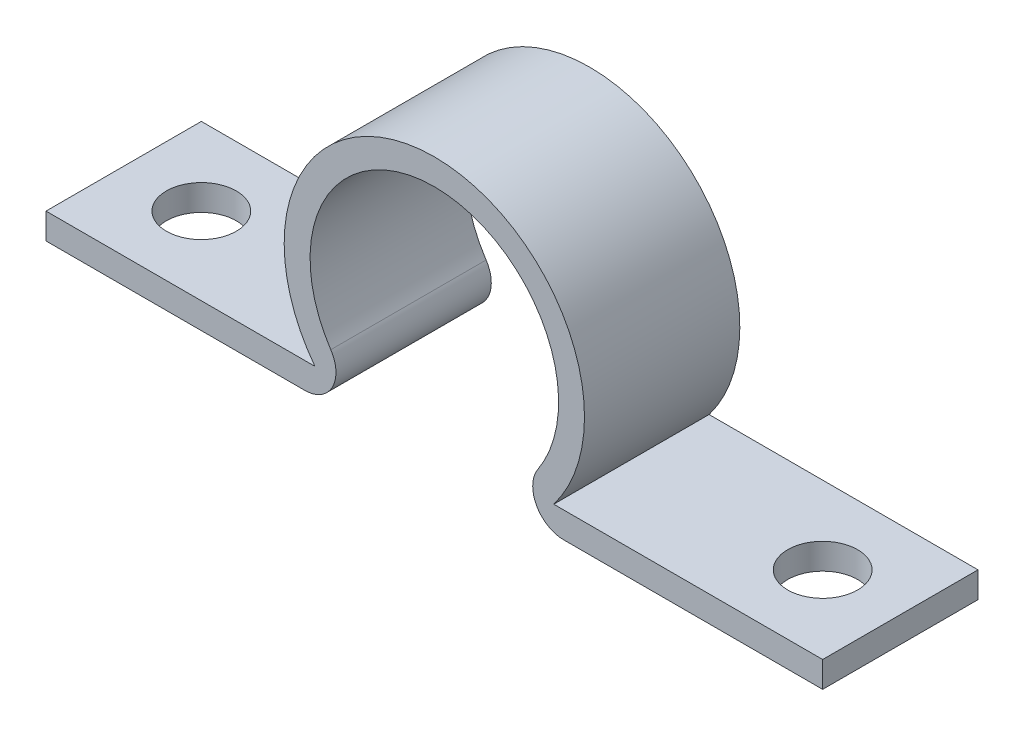
from build123d import *

# Parameters (mm, degrees)
BOSS_EXTRUDE1_DEPTH   = 30
M12_CLEARANCE_HOLE2_D = 13.5


with BuildPart() as part:
    # Sketch1 → Boss-Extrude1 (new body)
    with BuildSketch(Plane.XY):
        with BuildLine():
            Line((0, 0), (50, 0))
            ThreePointArc((50, 0), (55.286764074, 3.162725669), (55, 9.31662479))
            ThreePointArc((55, 9.31662479), (75, 46.583123952), (95, 9.31662479))
            ThreePointArc((95, 9.31662479), (94.713235926, 3.162725669), (100, 0))
            Line((100, 0), (150, 0))
            Line((150, 0), (150, 5))
            Line((150, 5), (98.061521027, 5))
            ThreePointArc((98.061521027, 5), (75, 51.583123952), (51.938478973, 5))
            Line((51.938478973, 5), (5, 5))
            Line((5, 5), (0, 5))
            Line((0, 5), (0, 0))
        make_face()
    extrude(amount=BOSS_EXTRUDE1_DEPTH)

    # M12 Clearance Hole2 (through all)
    with Locations(Plane(origin=(0, 5, 0), x_dir=(1, 0, 0), z_dir=(0, 1, 0))):
        with Locations((15, -15), (135, -15)):
            Hole(M12_CLEARANCE_HOLE2_D / 2)


solid = part.part
